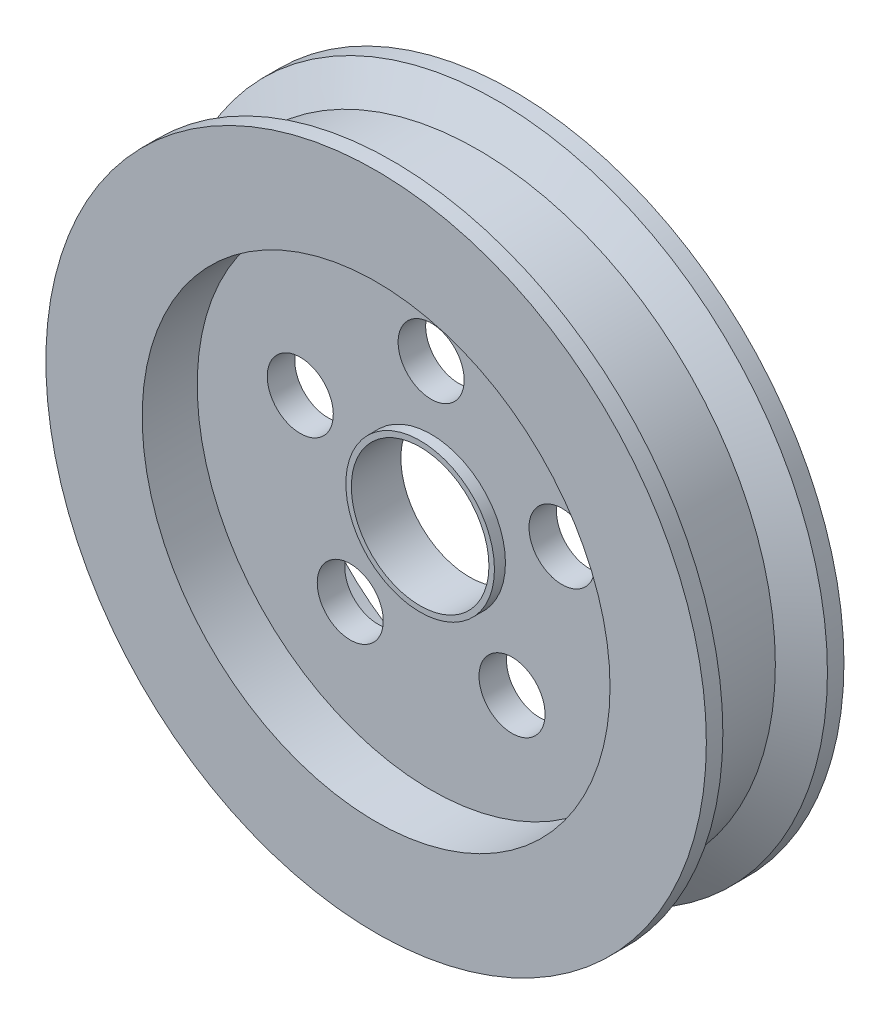
from build123d import *

# Parameters (mm, degrees)
SKETCH1_R                = 60
SKETCH1_R_2              = 12.5
BOSS_EXTRUDE1_DEPTH      = 12.5
SKETCH2_R                = 42.5
CUT_EXTRUDE1_DEPTH       = 10
SKETCH3_R                = 6
CUT_EXTRUDE2_DEPTH       = 16
CIRPATTERN1_COUNT        = 5
SKETCH5_R                = 13.5
SKETCH5_R_2              = 12.5
BOSS_EXTRUDE3_DEPTH      = 2
BOSS_EXTRUDE3_DEPTH_BACK = 7


with BuildPart() as part:
    # Sketch1 → Boss-Extrude1 (new body, symmetric)
    with BuildSketch(Plane.XY):
        Circle(SKETCH1_R)
        Circle(SKETCH1_R_2, mode=Mode.SUBTRACT)
    extrude(amount=BOSS_EXTRUDE1_DEPTH, both=True)

    # Sketch2 → Cut-Extrude1 (cut)
    with BuildSketch(Plane.XY.offset(12.5)):
        Circle(SKETCH2_R)
    cut_extrude1 = extrude(amount=-CUT_EXTRUDE1_DEPTH, mode=Mode.SUBTRACT)

    # Mirror1: Cut-Extrude1 across plane
    add(cut_extrude1.mirror(Plane.XY), mode=Mode.SUBTRACT)

    # Sketch3 → Cut-Extrude2 (cut, through all)
    with BuildSketch(Plane.XY.offset(2.5)):
        with Locations((0, 25)):
            Circle(SKETCH3_R)
    cut_extrude2 = extrude(amount=-CUT_EXTRUDE2_DEPTH, mode=Mode.SUBTRACT)

    # CirPattern1: Cut-Extrude2 ×5 about axis
    cirpattern1_axis = Axis((0, 0, 0), (0, 0, 1))
    for i in range(1, CIRPATTERN1_COUNT):
        add(cut_extrude2.rotate(cirpattern1_axis, i * 360 / CIRPATTERN1_COUNT), mode=Mode.SUBTRACT)

    # Sketch4 → Cut-Revolve1 (revolve, cut)
    with BuildSketch(Plane(origin=(0, 0, 0), x_dir=(1, 0, 0), z_dir=(0, 1, 0))):
        Polygon((60, 9.5), (54, 6.035898385), (54, -6.035898385), (60, -9.5), align=None)
    revolve(axis=Axis((0, 0, 0), (0, 0, -1)), mode=Mode.SUBTRACT)

    # Sketch5 → Boss-Extrude3 (add, two sides)
    with BuildSketch(Plane.XY.offset(2.5)) as boss_extrude3_sk:
        Circle(SKETCH5_R)
        Circle(SKETCH5_R_2, mode=Mode.SUBTRACT)
    extrude(amount=BOSS_EXTRUDE3_DEPTH)
    extrude(boss_extrude3_sk.sketch, amount=-BOSS_EXTRUDE3_DEPTH_BACK)


solid = part.part
